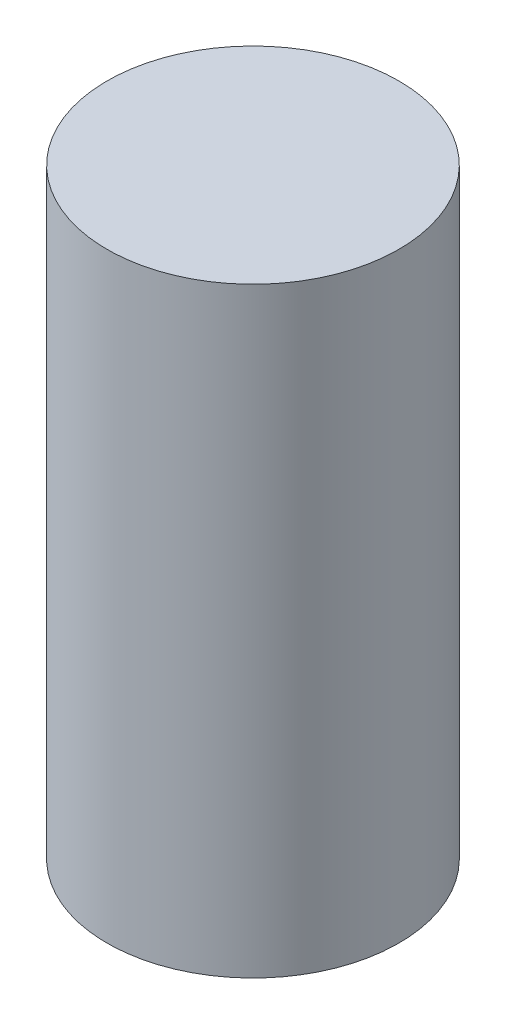
from build123d import *


with BuildPart() as part:
    # Sketch1 → Revolve1 (revolve)
    with BuildSketch(Plane.XY):
        Polygon((0, 0), (0.762, 0), (0.762, 8.89), (-1.397, 8.89), (-1.397, 5.08), (0, 5.08), align=None)
    revolve(axis=Axis((-1.397, 0.150539844, 0), (0, 1, 0)))


solid = part.part
